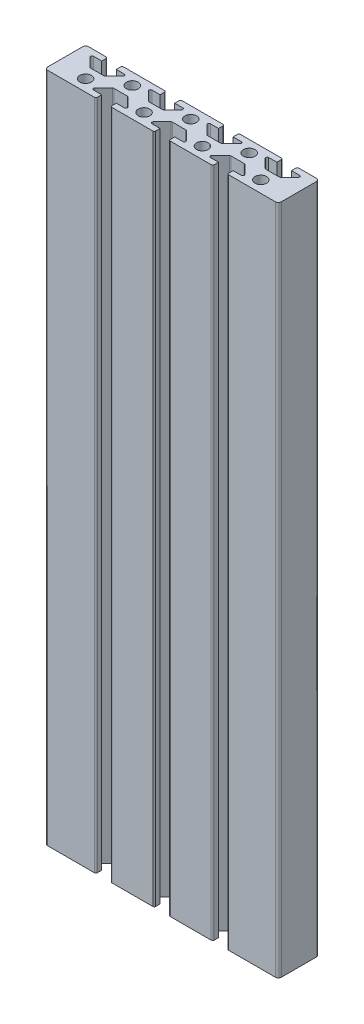
from build123d import *

# Parameters (mm, degrees)
SKETCH1_R           = 2
BOSS_EXTRUDE1_DEPTH = 230
FILLET1_R           = 0.5
FILLET2_R           = 0.5
FILLET3_R           = 1
SKETCH2_R           = 2.5
CUT_EXTRUDE2_DEPTH  = 230
SKETCH3_R           = 5.5
CUT_EXTRUDE3_DEPTH  = 7
SKETCH4_R           = 2.5
CUT_EXTRUDE4_DEPTH  = 7
SKETCH5_R           = 5.5
CUT_EXTRUDE5_DEPTH  = 7


with BuildPart() as part:
    # Sketch1 → Boss-Extrude1 (new body)
    with BuildSketch(Plane(origin=(0, 0, 0), x_dir=(1, 0, 0), z_dir=(0, 1, 0))):
        Polygon((67.5, 8), (63.5, 12), (67.5, 12), (67.5, 14), (52.5, 14), (52.5, 12), (56.5, 12), (52.5, 8), (47.5, 8), (43.5, 12), (47.5, 12), (47.5, 14), (32.5, 14), (32.5, 12), (36.5, 12), (32.5, 8), (27.5, 8), (23.5, 12), (27.5, 12), (27.5, 14), (12.5, 14), (12.5, 12), (16.5, 12), (12.5, 8), (7.5, 8), (3.5, 12), (7.5, 12), (7.5, 14), (0, 14), (0, 0), (17.5, 0), (17.5, 2), (13.5, 2), (17.5, 6), (22.5, 6), (26.5, 2), (22.5, 2), (22.5, 0), (37.5, 0), (37.5, 2), (33.5, 2), (37.5, 6), (42.5, 6), (46.5, 2), (42.5, 2), (42.5, 0), (57.5, 0), (57.5, 2), (53.5, 2), (57.5, 6), (62.5, 6), (66.5, 2), (62.5, 2), (62.5, 0), (80, 0), (80, 14), (72.5, 14), (72.5, 12), (76.5, 12), (72.5, 8), align=None)
        with Locations((10, 4)):
            Circle(SKETCH1_R, mode=Mode.SUBTRACT)
        with Locations((30, 4)):
            Circle(SKETCH1_R, mode=Mode.SUBTRACT)
        with Locations((50, 4)):
            Circle(SKETCH1_R, mode=Mode.SUBTRACT)
        with Locations((70, 4)):
            Circle(SKETCH1_R, mode=Mode.SUBTRACT)
        with Locations((20, 10)):
            Circle(SKETCH1_R, mode=Mode.SUBTRACT)
        with Locations((40, 10)):
            Circle(SKETCH1_R, mode=Mode.SUBTRACT)
        with Locations((60, 10)):
            Circle(SKETCH1_R, mode=Mode.SUBTRACT)
    extrude(amount=BOSS_EXTRUDE1_DEPTH)

    # Fillet1
    fillet1_edges = [part.edges().sort_by_distance(p)[0] for p in [
        (7.5, 115, -14),
        (3.5, 115, -12),
        (7.5, 115, -8),
        (12.5, 115, -8),
        (16.5, 115, -12),
        (12.5, 115, -14),
        (27.5, 115, -14),
        (23.5, 115, -12),
        (27.5, 115, -8),
        (32.5, 115, -8),
        (36.5, 115, -12),
        (32.5, 115, -14),
        (47.5, 115, -14),
        (43.5, 115, -12),
        (47.5, 115, -8),
        (52.5, 115, -8),
        (56.5, 115, -12),
        (52.5, 115, -14),
        (67.5, 115, -14),
        (63.5, 115, -12),
        (67.5, 115, -8),
        (72.5, 115, -8),
        (76.5, 115, -12),
        (72.5, 115, -14),
    ]]
    fillet(fillet1_edges, radius=FILLET1_R)

    # Fillet2
    fillet2_edges = [part.edges().sort_by_distance(p)[0] for p in [
        (26.5, 115, -2),
        (22.5, 115, -6),
        (17.5, 115, -6),
        (13.5, 115, -2),
        (17.5, 115, 0),
        (62.5, 115, 0),
        (66.5, 115, -2),
        (62.5, 115, -6),
        (57.5, 115, -6),
        (53.5, 115, -2),
        (57.5, 115, 0),
        (42.5, 115, 0),
        (46.5, 115, -2),
        (42.5, 115, -6),
        (37.5, 115, -6),
        (33.5, 115, -2),
        (37.5, 115, 0),
        (22.5, 115, 0),
    ]]
    fillet(fillet2_edges, radius=FILLET2_R)

    # Fillet3
    fillet3_edges = [part.edges().sort_by_distance(p)[0] for p in [
        (0, 115, 0),
        (0, 115, -14),
        (80, 115, -14),
        (80, 115, 0),
    ]]
    fillet(fillet3_edges, radius=FILLET3_R)

    # Sketch2 → Cut-Extrude2 (cut)
    with BuildSketch(Plane(origin=(0, 0, -14), x_dir=(-1, 0, 0), z_dir=(0, 0, -1))):
        with Locations((-40, 10)):
            Circle(SKETCH2_R)
    extrude(amount=-CUT_EXTRUDE2_DEPTH, mode=Mode.SUBTRACT)

    # Sketch3 → Cut-Extrude3 (cut)
    with BuildSketch(Plane(origin=(0, 0, -14), x_dir=(-1, 0, 0), z_dir=(0, 0, -1))):
        with Locations((-40, 10)):
            Circle(SKETCH3_R)
    extrude(amount=-CUT_EXTRUDE3_DEPTH, mode=Mode.SUBTRACT)

    # Sketch4 → Cut-Extrude4 (cut)
    with BuildSketch(Plane(origin=(0, 0, -14), x_dir=(-1, 0, 0), z_dir=(0, 0, -1))):
        with Locations((-40, 220)):
            Circle(SKETCH4_R)
    extrude(amount=-CUT_EXTRUDE4_DEPTH, mode=Mode.SUBTRACT)

    # Sketch5 → Cut-Extrude5 (cut)
    with BuildSketch(Plane(origin=(0, 0, -14), x_dir=(-1, 0, 0), z_dir=(0, 0, -1))):
        with Locations((-40, 220)):
            Circle(SKETCH5_R)
    extrude(amount=-CUT_EXTRUDE5_DEPTH, mode=Mode.SUBTRACT)


solid = part.part
